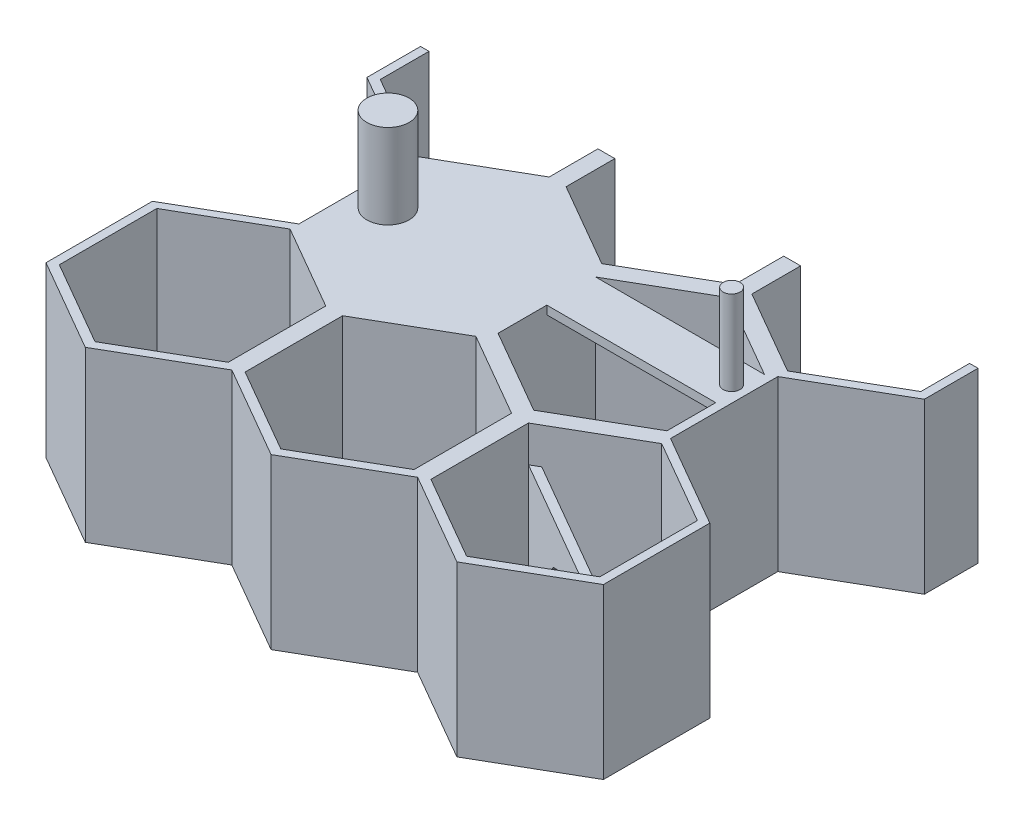
from build123d import *

# Parameters (mm, degrees)
BOSS_EXTRUDE2_DEPTH = 20
CUT_EXTRUDE1_DEPTH  = 21
CUT_EXTRUDE2_DEPTH  = 21
SKETCH4_W           = 20
SKETCH4_H           = 5.773502692
BOSS_EXTRUDE3_DEPTH = 1
BOSS_EXTRUDE6_DEPTH = 1
SKETCH6_R           = 1
SKETCH6_R_2         = 2.5
BOSS_EXTRUDE7_DEPTH = 10


with BuildPart() as part:
    # Sketch1 → Boss-Extrude2 (new body)
    with BuildSketch(Plane(origin=(0, 0, 0), x_dir=(1, 0, 0), z_dir=(0, 1, 0))):
        Polygon((21, -13.279056191), (21, -19.052558883), (23, -19.052558883), (23, -13.279056191), (33, -7.505553499), (43, -13.279056191), (43, -19.052558883), (45, -19.052558883), (45, -13.279056191), (55, -7.505553499), (65, -13.279056191), (65, -19.052558883), (67, -19.052558883), (67, -13.279056191), (77, -7.505553499), (77, 7.400435733), (67, 13.173938425), (67, 24.720943809), (77, 30.494446501), (77, 38), (76, 38), (76, 32.226497308), (66, 26.452994616), (56, 32.226497308), (56, 38), (54, 38), (54, 32.226497308), (44, 26.452994616), (34, 32.226497308), (34, 38), (32, 38), (32, 32.226497308), (22, 26.452994616), (12, 32.226497308), (12, 38), (11, 38), (11, 30.494446501), (21, 24.720943809), (21, 13.173938425), (11, 7.400435733), (11, -7.505553499), align=None)
        Polygon((12, 5.773502692), (22, 11.547005384), (32, 5.773502692), (32, -5.773502692), (22, -11.547005384), (12, -5.773502692), align=None, mode=Mode.SUBTRACT)
        Polygon((34, 5.773502692), (44, 11.547005384), (54, 5.773502692), (54, -5.773502692), (44, -11.547005384), (34, -5.773502692), align=None, mode=Mode.SUBTRACT)
        Polygon((56, 5.773502692), (66, 11.547005384), (76, 5.773502692), (76, -5.773502692), (66, -11.547005384), (56, -5.773502692), align=None, mode=Mode.SUBTRACT)
        Polygon((43, 13.173938425), (33, 7.400435733), (23, 13.173938425), (23, 24.720943809), (33, 30.494446501), (43, 24.720943809), align=None, mode=Mode.SUBTRACT)
        Polygon((65, 13.173938425), (55, 7.400435733), (45, 13.173938425), (45, 24.720943809), (55, 30.494446501), (65, 24.720943809), align=None, mode=Mode.SUBTRACT)
    extrude(amount=BOSS_EXTRUDE2_DEPTH)

    # Sketch2 → Cut-Extrude1 (cut, through all)
    with BuildSketch(Plane(origin=(0, 20, 0), x_dir=(1, 0, 0), z_dir=(0, 1, 0))):
        Polygon((11, 6.245735195), (22, 12.596588156), (22, 25.298294078), (11, 31.649147039), (2.295872016, -19.052558883), (22, -19.052558883), (22, -12.701705922), (11, -6.350852961), align=None)
        Polygon((77, 31.649147039), (85.704127984, -19.052558883), (66, -19.052558883), (66, -12.701705922), (77, -6.350852961), (77, 6.245735195), (66, 12.596588156), (66, 25.298294078), align=None)
    extrude(amount=-CUT_EXTRUDE1_DEPTH, mode=Mode.SUBTRACT)

    # Sketch3 → Cut-Extrude2 (cut, through all)
    with BuildSketch(Plane(origin=(0, 20, 0), x_dir=(1, 0, 0), z_dir=(0, 1, 0))):
        Polygon((22, -12.701705922), (33, -6.350852961), (44, -12.701705922), (55, -6.350852961), (66, -12.701705922), (66, -19.052558883), (22, -19.052558883), align=None)
    extrude(amount=-CUT_EXTRUDE2_DEPTH, mode=Mode.SUBTRACT)

    # Sketch4 → Boss-Extrude3 (add)
    with BuildSketch(Plane(origin=(0, 20, 0), x_dir=(1, 0, 0), z_dir=(0, 1, 0))):
        Polygon((33, 7.400435733), (43, 13.173938425), (43, 24.720943809), (33, 30.494446501), (23, 24.720943809), (23, 13.173938425), align=None)
        with Locations((55, 21.834192463)):
            Rectangle(SKETCH4_W, SKETCH4_H)
    extrude(amount=-BOSS_EXTRUDE3_DEPTH)

    # Sketch5 → Boss-Extrude6 (add)
    with BuildSketch(Plane(origin=(16.5, 0, -28.578838325), x_dir=(-0.866025404, 0, -0.5), z_dir=(0.5, 0, -0.866025404))):
        Polygon((-45.610671266, 0), (-45.610671266, 15.710490214), (-60.397494553, 15.710490214), (-68.704682034, 15.710490214), (-58.542381094, 12.987509884), (-53.745304613, 10.750596384), (-49.18414323, 6.189435001), align=None)
    extrude(amount=BOSS_EXTRUDE6_DEPTH)

    # Sketch6 → Boss-Extrude7 (add)
    with BuildSketch(Plane(origin=(0, 20, 0), x_dir=(1, 0, 0), z_dir=(0, 1, 0))):
        with Locations((64.099793447, 21.726394301)):
            Circle(SKETCH6_R)
        with Locations((25.613716887, 19.524193735)):
            Circle(SKETCH6_R_2)
    extrude(amount=BOSS_EXTRUDE7_DEPTH)


solid = part.part
